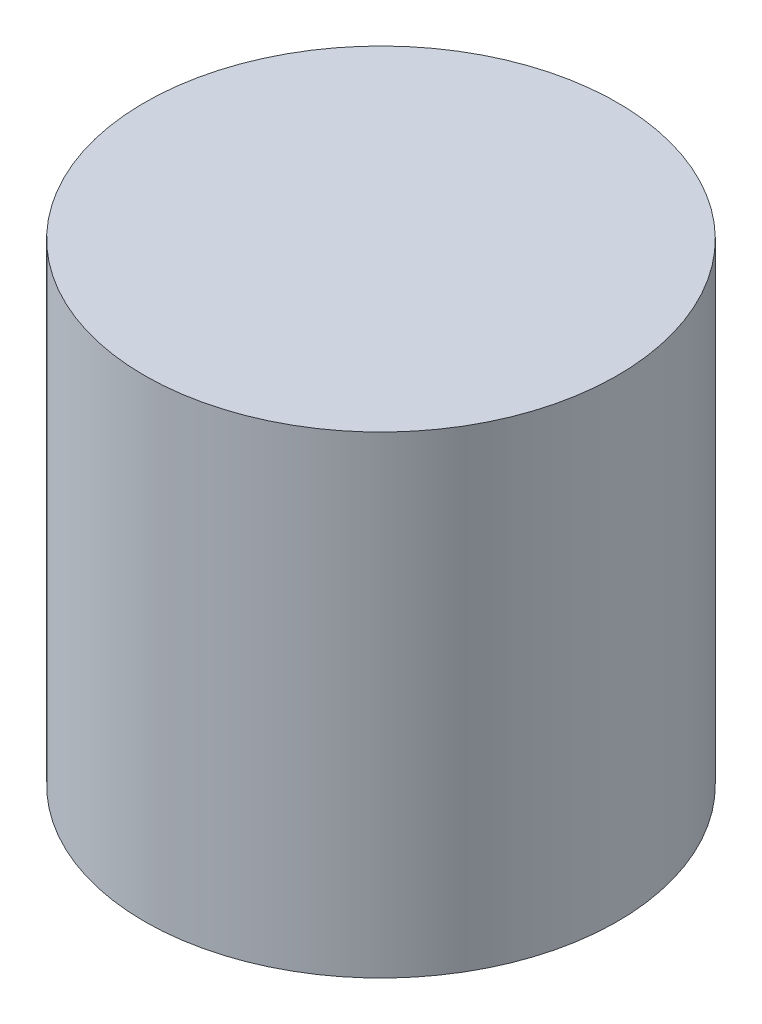
from build123d import *

# Parameters (mm, degrees)
SKETCH1_R           = 15
BOSS_EXTRUDE1_DEPTH = 30


with BuildPart() as part:
    # Sketch1 → Boss-Extrude1 (new body)
    with BuildSketch(Plane(origin=(0, 0, 0), x_dir=(1, 0, 0), z_dir=(0, 1, 0))):
        Circle(SKETCH1_R)
    extrude(amount=BOSS_EXTRUDE1_DEPTH)


solid = part.part
